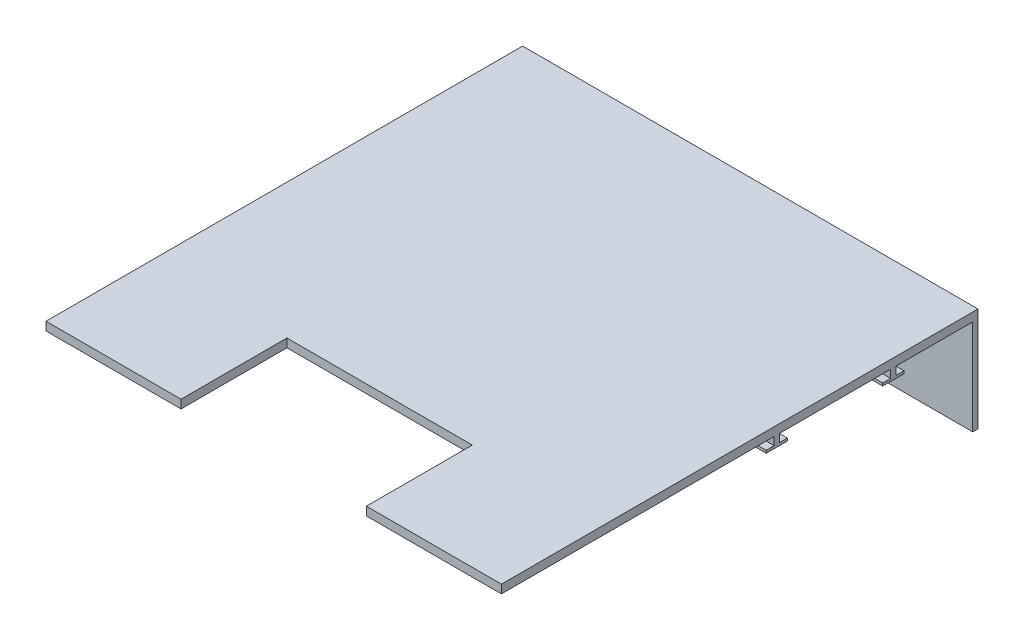
from build123d import *

# Parameters (mm, degrees)
SKETCH1_W           = 430
SKETCH1_H           = 450
BOSS_EXTRUDE1_DEPTH = 8
SKETCH2_W           = 175
SKETCH2_H           = 100
CUT_EXTRUDE1_DEPTH  = 10
SKETCH4_R           = 3.5
BOSS_EXTRUDE3_DEPTH = 15
BOSS_EXTRUDE4_DEPTH = 90
SKETCH9_W           = 430
SKETCH9_H           = 5
BOSS_EXTRUDE6_DEPTH = 7.5
SKETCH10_W          = 430
SKETCH10_H          = 20
BOSS_EXTRUDE7_DEPTH = 2.5


with BuildPart() as part:
    # Sketch1 → Boss-Extrude1 (new body)
    with BuildSketch(Plane(origin=(0, 0, 0), x_dir=(1, 0, 0), z_dir=(0, 1, 0))):
        with Locations((215, 225)):
            Rectangle(SKETCH1_W, SKETCH1_H)
    extrude(amount=BOSS_EXTRUDE1_DEPTH)

    # Sketch2 → Cut-Extrude1 (cut)
    with BuildSketch(Plane(origin=(0, 8, 0), x_dir=(1, 0, 0), z_dir=(0, 1, 0))):
        with Locations((215, 50)):
            Rectangle(SKETCH2_W, SKETCH2_H)
    extrude(amount=-CUT_EXTRUDE1_DEPTH, mode=Mode.SUBTRACT)

    # Sketch4 → Boss-Extrude3 (add)
    with BuildSketch(Plane.XZ):
        with Locations((30, -217)):
            Circle(SKETCH4_R)
        with Locations((400, -217)):
            Circle(SKETCH4_R)
    extrude(amount=BOSS_EXTRUDE3_DEPTH)

    # Sketch5 → Boss-Extrude4 (add)
    with BuildSketch(Plane.XZ):
        Polygon((5.000626144, -445), (0, -445), (0, -450), (430, -450), (430, -445), (429.008283612, -445), align=None)
    extrude(amount=BOSS_EXTRUDE4_DEPTH)

    # Sketch9 → Boss-Extrude6 (add)
    with BuildSketch(Plane.XZ):
        with Locations((215, -370)):
            Rectangle(SKETCH9_W, SKETCH9_H)
    boss_extrude6 = extrude(amount=BOSS_EXTRUDE6_DEPTH)

    # Sketch10 → Boss-Extrude7 (add)
    with BuildSketch(Plane.XZ.offset(7.5)):
        with Locations((215, -370)):
            Rectangle(SKETCH10_W, SKETCH10_H)
    boss_extrude7 = extrude(amount=BOSS_EXTRUDE7_DEPTH)

    # Mirror9: Boss-Extrude6, Boss-Extrude7 across plane
    add(boss_extrude6.mirror(Plane.XY.offset(-315)))
    add(boss_extrude7.mirror(Plane.XY.offset(-315)))


solid = part.part
